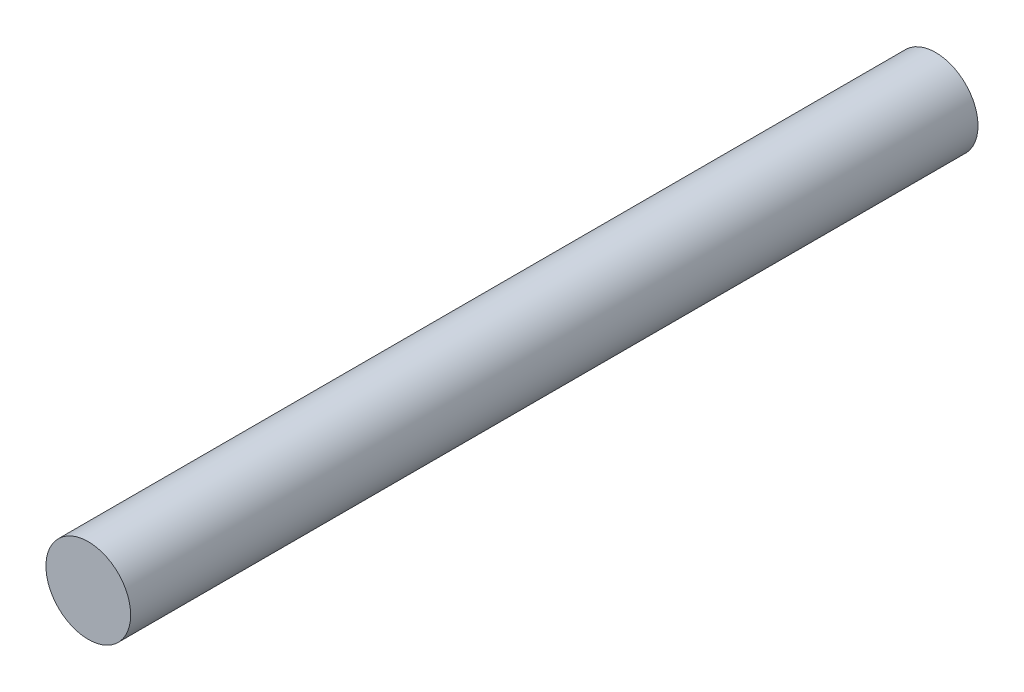
from build123d import *

# Parameters (mm, degrees)
SKETCH_1_R      = 1
EXTRUDE_1_DEPTH = 10


with BuildPart() as part:
    # 草图1 → 凸台-拉伸1 (new body, symmetric)
    with BuildSketch(Plane.XY):
        Circle(SKETCH_1_R)
    extrude(amount=EXTRUDE_1_DEPTH, both=True)


solid = part.part
